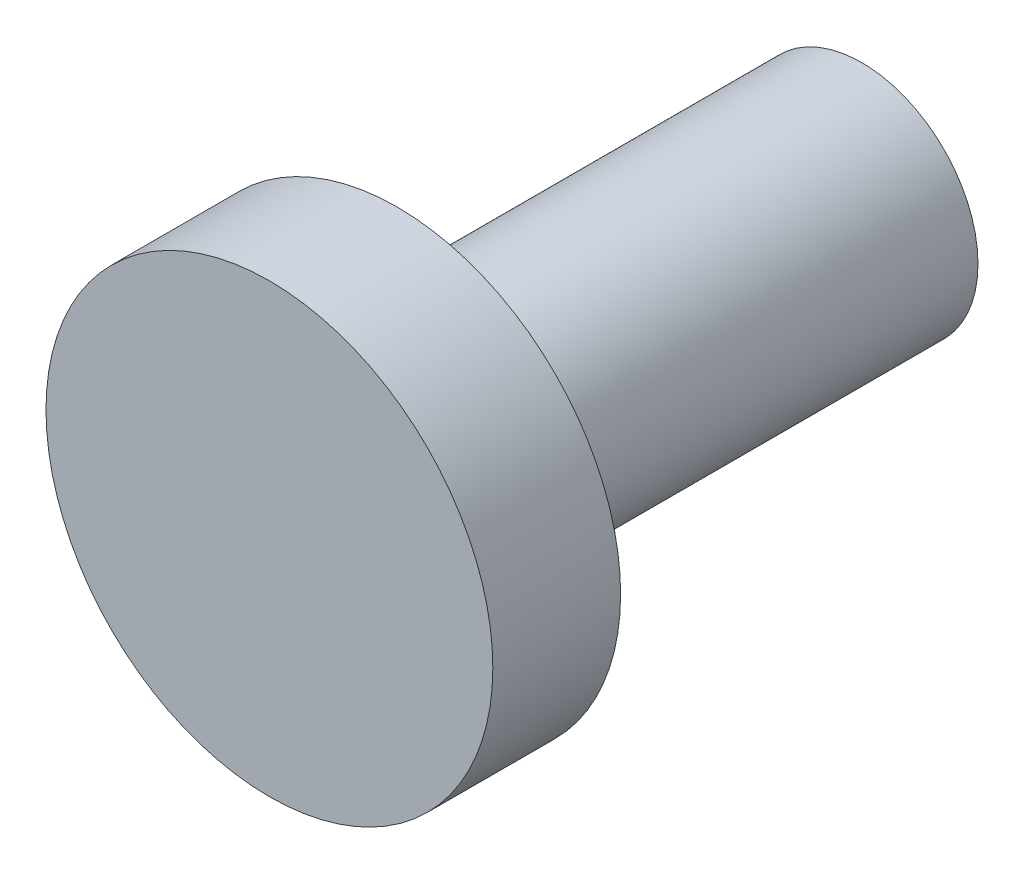
from build123d import *

# Parameters (mm, degrees)
SKETCH_0_R              = 2.885
SALIENTE_EXTRUIR1_DEPTH = 1.65
CORTE_EXTERIOR_R        = 1.5
SALIENTE_EXTRUIR2_DEPTH = 6


with BuildPart() as part:
    # Sketch 0 → Saliente-Extruir1 (new body)
    with BuildSketch(Plane.XY):
        with Locations((33.908333333, 19.916666667)):
            Circle(SKETCH_0_R)
    extrude(amount=SALIENTE_EXTRUIR1_DEPTH)

    # Corte exterior → Saliente-Extruir2 (add)
    with BuildSketch(Plane.XY):
        with Locations((33.908333333, 19.916666667)):
            Circle(CORTE_EXTERIOR_R)
    extrude(amount=-SALIENTE_EXTRUIR2_DEPTH)


solid = part.part
